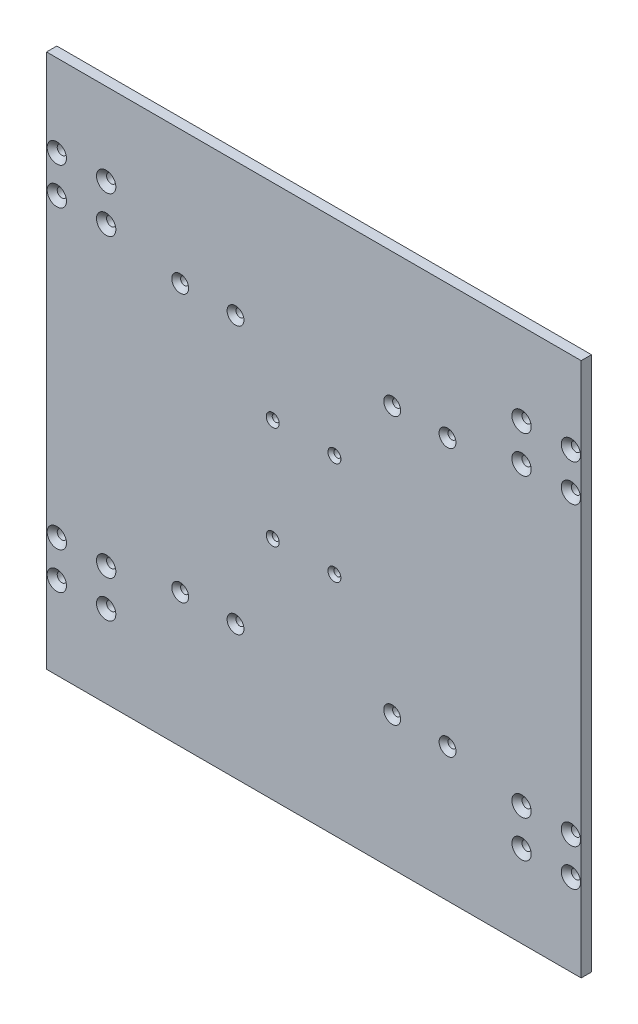
from build123d import *

# Parameters (mm, degrees)
SKETCH1_W                                         = 260
SKETCH1_H                                         = 260
BOSS_EXTRUDE1_DEPTH                               = 5
SKETCH3_R                                         = 1.5
TEMP_SENSOR_DEPTH                                 = 2
CSK_FOR_M4_FLAT_HEAD_MACHINE_SCREW1_D             = 4.5
CSK_FOR_M4_FLAT_HEAD_MACHINE_SCREW1_CSINK_D       = 9.4
CSK_FOR_M4_FLAT_HEAD_MACHINE_SCREW1_CSINK_ANGLE   = 90
CSK_FOR_M3_5_FLAT_HEAD_MACHINE_SCREW1_D           = 3.9
CSK_FOR_M3_5_FLAT_HEAD_MACHINE_SCREW1_CSINK_D     = 8.2
CSK_FOR_M3_5_FLAT_HEAD_MACHINE_SCREW1_CSINK_ANGLE = 90
CSK_FOR_M3_FLAT_HEAD_MACHINE_SCREW1_D             = 3.4
CSK_FOR_M3_FLAT_HEAD_MACHINE_SCREW1_CSINK_D       = 6.3
CSK_FOR_M3_FLAT_HEAD_MACHINE_SCREW1_CSINK_ANGLE   = 90


with BuildPart() as part:
    # Sketch1 → Boss-Extrude1 (new body)
    with BuildSketch(Plane.XY):
        with Locations((-130, 130)):
            Rectangle(SKETCH1_W, SKETCH1_H)
    extrude(amount=BOSS_EXTRUDE1_DEPTH)

    # Sketch3 → temp. sensor (cut)
    with BuildSketch(Plane(origin=(0, 0, 0), x_dir=(-1, 0, 0), z_dir=(0, 0, -1))):
        with Locations((135, 135)):
            Circle(SKETCH3_R)
    extrude(amount=-TEMP_SENSOR_DEPTH, mode=Mode.SUBTRACT)

    # CSK for M4 Flat Head Machine Screw1 (through all)
    with Locations(Plane.XY.offset(5)):
        with Locations((-255, 220), (-231, 220), (-231, 202), (-255, 202), (-5, 202), (-29, 202), (-29, 220), (-5, 220), (-29, 58), (-5, 58), (-5, 40), (-29, 40), (-255, 40), (-231, 40), (-231, 58), (-255, 58)):
            CounterSinkHole(CSK_FOR_M4_FLAT_HEAD_MACHINE_SCREW1_D / 2, CSK_FOR_M4_FLAT_HEAD_MACHINE_SCREW1_CSINK_D / 2, counter_sink_angle=CSK_FOR_M4_FLAT_HEAD_MACHINE_SCREW1_CSINK_ANGLE)

    # CSK for M3.5 Flat Head Machine Screw1 (through all)
    with Locations(Plane.XY.offset(5)):
        with Locations((-195, 195), (-168.093, 195), (-91.907, 195), (-65, 195), (-65, 65), (-91.907, 65), (-168.093, 65), (-195, 65)):
            CounterSinkHole(CSK_FOR_M3_5_FLAT_HEAD_MACHINE_SCREW1_D / 2, CSK_FOR_M3_5_FLAT_HEAD_MACHINE_SCREW1_CSINK_D / 2, counter_sink_angle=CSK_FOR_M3_5_FLAT_HEAD_MACHINE_SCREW1_CSINK_ANGLE)

    # CSK for M3 Flat Head Machine Screw1 (through all)
    with Locations(Plane.XY.offset(5)):
        with Locations((-120, 110), (-150, 110), (-150, 160), (-120, 160)):
            CounterSinkHole(CSK_FOR_M3_FLAT_HEAD_MACHINE_SCREW1_D / 2, CSK_FOR_M3_FLAT_HEAD_MACHINE_SCREW1_CSINK_D / 2, counter_sink_angle=CSK_FOR_M3_FLAT_HEAD_MACHINE_SCREW1_CSINK_ANGLE)


solid = part.part
